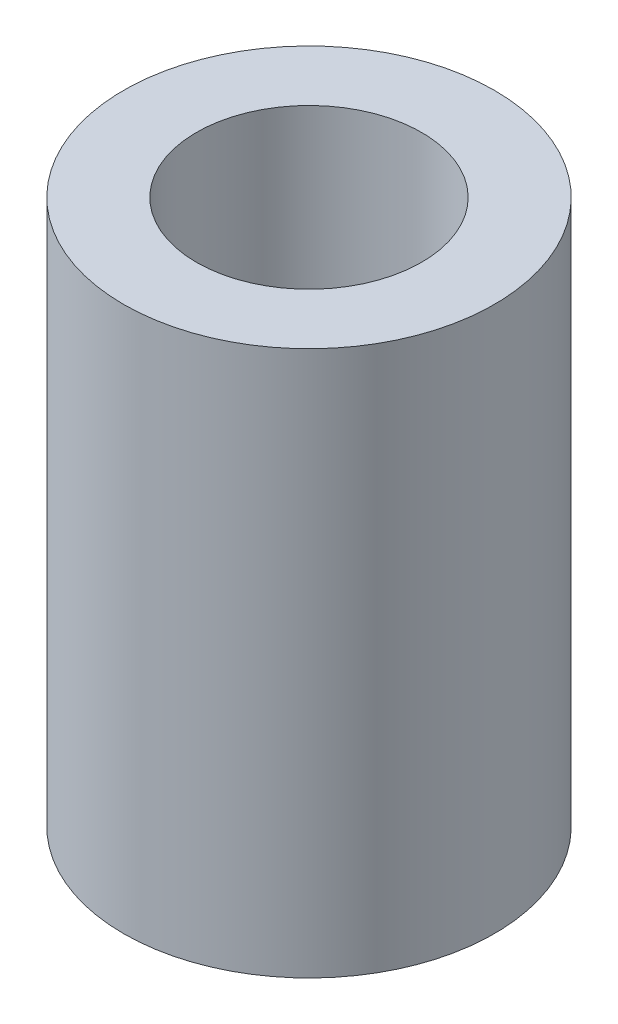
from build123d import *

# Parameters (mm, degrees)
SKETCH1_R           = 7
SKETCH1_R_2         = 4.25
BOSS_EXTRUDE1_DEPTH = 20.575016


with BuildPart() as part:
    # Sketch1 → Boss-Extrude1 (new body)
    with BuildSketch(Plane(origin=(0, 0, 0), x_dir=(1, 0, 0), z_dir=(0, 1, 0))):
        Circle(SKETCH1_R)
        Circle(SKETCH1_R_2, mode=Mode.SUBTRACT)
    extrude(amount=BOSS_EXTRUDE1_DEPTH)


solid = part.part
